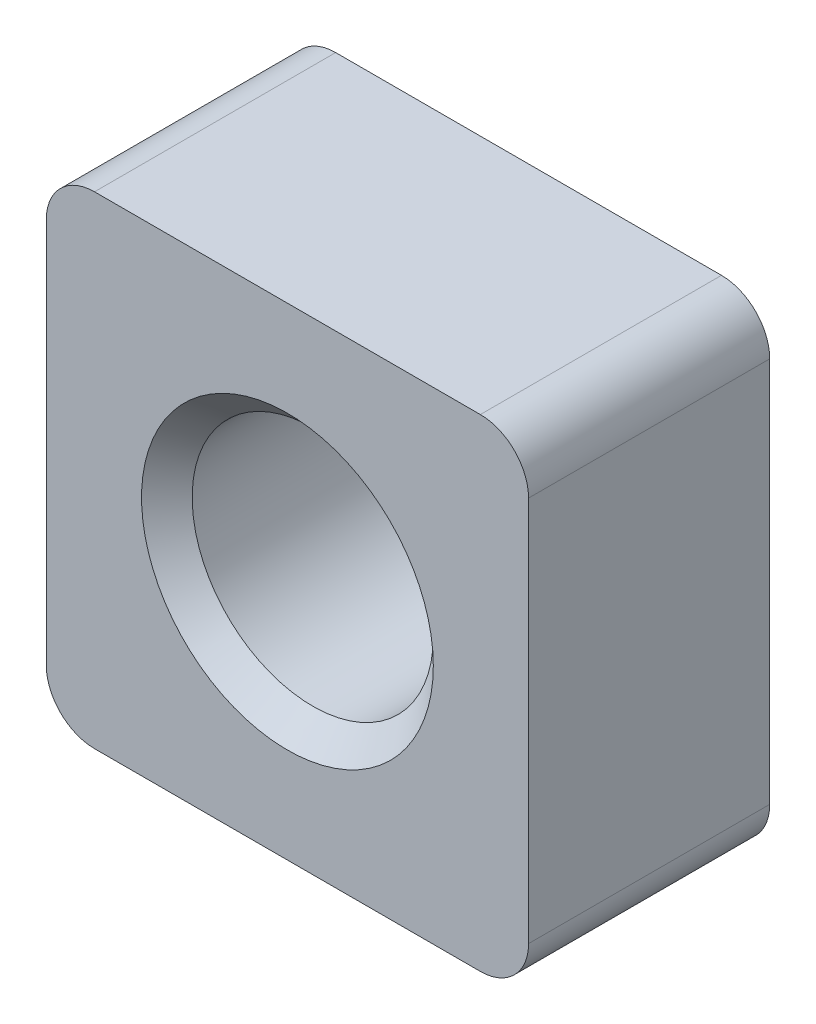
from build123d import *

# Parameters (mm, degrees)
SKETCH_1_W      = 10
SKETCH_1_H      = 10
EXTRUDE_1_DEPTH = 5
FILLET_1_R      = 1


with BuildPart() as part:
    # Эскиз1 → Бобышка-Вытянуть1 (new body)
    with BuildSketch(Plane.XY):
        Rectangle(SKETCH_1_W, SKETCH_1_H)
    extrude(amount=EXTRUDE_1_DEPTH)

    # Эскиз3 → Отверстие обработанное метчиком M61 (revolve, cut)
    with BuildSketch(Plane(origin=(0, 0, 5), x_dir=(0, -1, 0), z_dir=(1, 0, 0))):
        Polygon((0, 0), (0, 5), (3.025, 5), (2.5, 4.475), (2.5, 0.525), (3.025, 0), align=None)
    revolve(axis=Axis((0, 0, 11.35), (0, 0, -1)), mode=Mode.SUBTRACT)

    # Скругление1
    fillet_1_edges = [part.edges().sort_by_distance(p)[0] for p in [
        (5, -5, 2.5),
        (-5, -5, 2.5),
        (-5, 5, 2.5),
        (5, 5, 2.5),
    ]]
    fillet(fillet_1_edges, radius=FILLET_1_R)


solid = part.part
